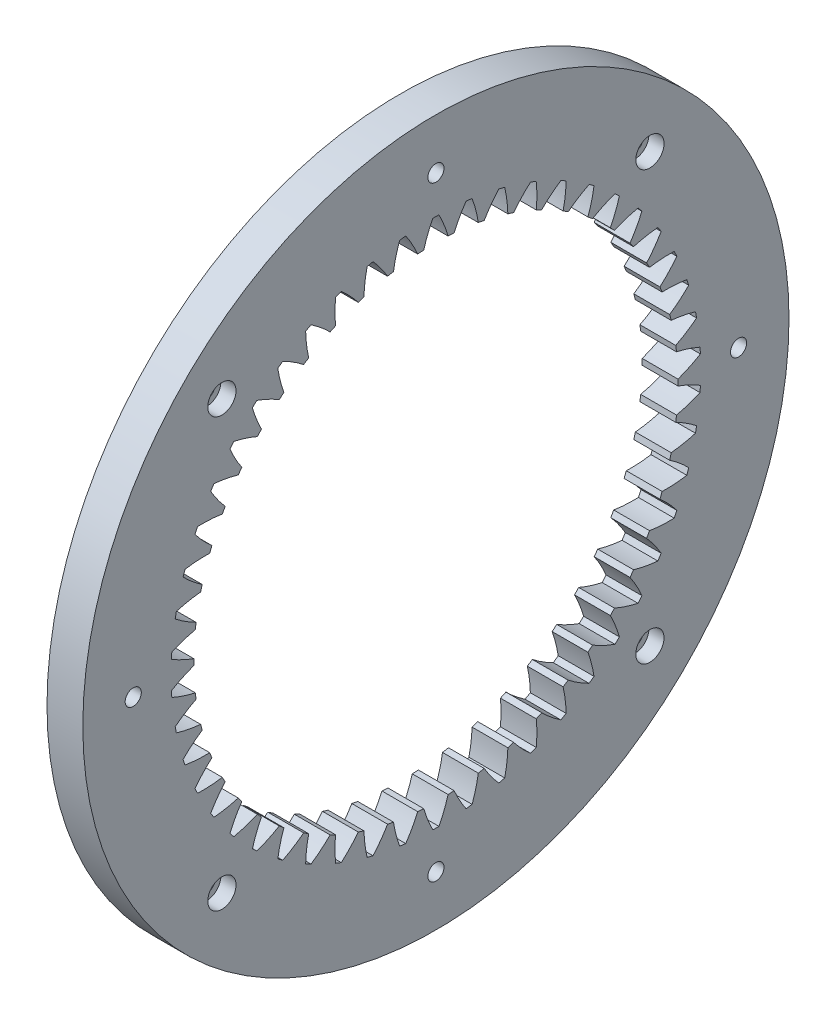
from build123d import *

# Parameters (mm, degrees)
BASPROSKE_W         = 15.2
BASPROSKE_H         = 22
TOOTHCUT_DEPTH      = 101.155079751
TEETHCUTS_COUNT     = 50
TEETHCUTS_ANGLE     = 352.8
SKETCH1_R           = 1.6
CUT_EXTRUDE1_DEPTH  = 16
SKETCH3_R           = 1.6
CUT_EXTRUDE3_DEPTH  = 16
SKETCH8_R           = 70
CUT_EXTRUDE8_DEPTH  = 8.1
SKETCH10_R          = 2.8
CUT_EXTRUDE10_DEPTH = 3
CUT_EXTRUDE11_DEPTH = 3


with BuildPart() as part:
    # BasProSke → Base-Revolve (revolve)
    with BuildSketch(Plane(origin=(0, 0, 0), x_dir=(1, 0, 0), z_dir=(0, 1, 0))):
        with Locations((7.6, 59)):
            Rectangle(BASPROSKE_W, BASPROSKE_H)
    revolve(axis=Axis((-10, 0, 0), (1, 0, 0)))

    # TooCutSke → ToothCut (cut, through all)
    with BuildSketch(Plane(origin=(0, 0, 0), x_dir=(0, 0, -1), z_dir=(1, 0, 0))):
        with BuildLine():
            ThreePointArc((2.426707814, 47.913185391), (1.628356337, 50.250450788), (0.603274723, 52.497533853))
            ThreePointArc((0.603274723, 52.497533853), (0, 52.501), (-0.603274723, 52.497533853))
            ThreePointArc((-0.603274723, 52.497533853), (-1.628356337, 50.250450788), (-2.426707814, 47.913185391))
            ThreePointArc((-2.426707814, 47.913185391), (0, 47.9746), (2.426707814, 47.913185391))
        make_face()
    toothcut = extrude(amount=TOOTHCUT_DEPTH, mode=Mode.SUBTRACT)

    # TeethCuts: ToothCut ×50 about axis
    teethcuts_axis = Axis((-10, 0, 0), (1, 0, 0))
    for i in range(1, TEETHCUTS_COUNT):
        add(toothcut.rotate(teethcuts_axis, i * TEETHCUTS_ANGLE / (TEETHCUTS_COUNT - 1)), mode=Mode.SUBTRACT)

    # Sketch1 → Cut-Extrude1 (cut)
    with BuildSketch(Plane(origin=(15.2, 0, 0), x_dir=(0, 0, -1), z_dir=(1, 0, 0))):
        with Locations((60, 0)):
            Circle(SKETCH1_R)
        with Locations((0, 60)):
            Circle(SKETCH1_R)
        with Locations((0, -60)):
            Circle(SKETCH1_R)
        with Locations((-60, 0)):
            Circle(SKETCH1_R)
    extrude(amount=-CUT_EXTRUDE1_DEPTH, mode=Mode.SUBTRACT)

    # Sketch3 → Cut-Extrude3 (cut)
    with BuildSketch(Plane(origin=(15.2, 0, 0), x_dir=(0, 0, -1), z_dir=(1, 0, 0))):
        with Locations((42.426406871, 42.426406871)):
            Circle(SKETCH3_R)
        with Locations((42.426406871, -42.426406871)):
            Circle(SKETCH3_R)
        with Locations((-42.426406871, -42.426406871)):
            Circle(SKETCH3_R)
        with Locations((-42.426406871, 42.426406871)):
            Circle(SKETCH3_R)
    extrude(amount=-CUT_EXTRUDE3_DEPTH, mode=Mode.SUBTRACT)

    # Sketch8 → Cut-Extrude8 (cut)
    with BuildSketch(Plane(origin=(15.2, 0, 0), x_dir=(0, 0, -1), z_dir=(1, 0, 0))):
        Circle(SKETCH8_R)
    extrude(amount=-CUT_EXTRUDE8_DEPTH, mode=Mode.SUBTRACT)

    # Sketch10 → Cut-Extrude10 (cut)
    with BuildSketch(Plane(origin=(7.1, 0, 0), x_dir=(0, 0, -1), z_dir=(1, 0, 0))):
        with Locations((-42.426406871, 42.426406871)):
            Circle(SKETCH10_R)
        with Locations((42.426406871, 42.426406871)):
            Circle(SKETCH10_R)
        with Locations((42.426406871, -42.426406871)):
            Circle(SKETCH10_R)
        with Locations((-42.426406871, -42.426406871)):
            Circle(SKETCH10_R)
    extrude(amount=-CUT_EXTRUDE10_DEPTH, mode=Mode.SUBTRACT)

    # Sketch11 → Cut-Extrude11 (cut)
    with BuildSketch(Plane.ZY):
        Polygon((63.233161507, 0), (61.616580754, 2.8), (58.383419246, 2.8), (56.766838493, 0), (58.383419246, -2.8), (61.616580754, -2.8), align=None)
        Polygon((0, 63.233161507), (-2.8, 61.616580754), (-2.8, 58.383419246), (0, 56.766838493), (2.8, 58.383419246), (2.8, 61.616580754), align=None)
        Polygon((0, -63.233161507), (2.8, -61.616580754), (2.8, -58.383419246), (0, -56.766838493), (-2.8, -58.383419246), (-2.8, -61.616580754), align=None)
        Polygon((-63.233161507, 0), (-61.616580754, -2.8), (-58.383419246, -2.8), (-56.766838493, 0), (-58.383419246, 2.8), (-61.616580754, 2.8), align=None)
    extrude(amount=-CUT_EXTRUDE11_DEPTH, mode=Mode.SUBTRACT)


solid = part.part
